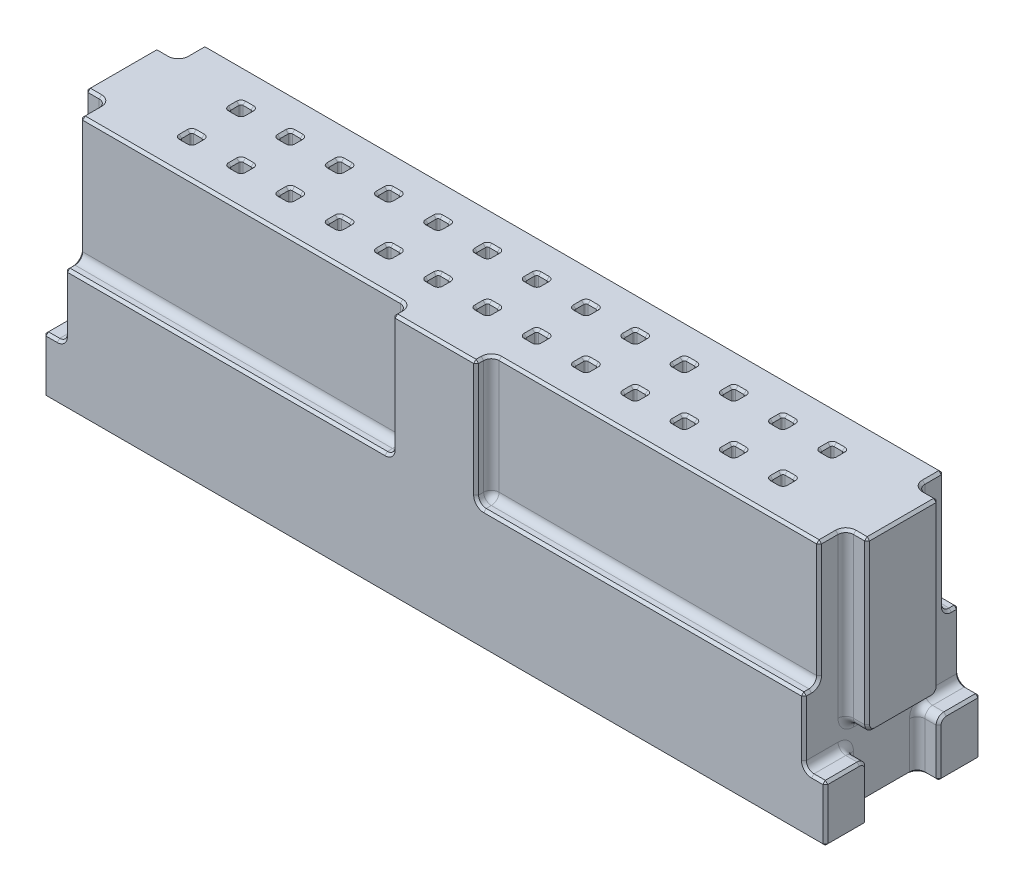
from build123d import *

# Parameters (mm, degrees)
SKETCH1_W            = 40.3098
SKETCH1_H            = 8.001
BOSS_EXTRUDE1_DEPTH  = 12.7
SKETCH2_W            = 1.1049
SKETCH2_H            = 2.159
CUT_EXTRUDE1_DEPTH   = 9.79932
CUT_EXTRUDE2_REACH   = 23.431
CUT_EXTRUDE2_START   = -8.73125
SKETCH4_W            = 1.1049
SKETCH4_H            = 3.683
SKETCH5_W            = 16.89989
SKETCH5_H            = 0.78613
SKETCH5_W_2          = 38.1
CUT_EXTRUDE3_DEPTH   = 6.4008
SKETCH6_W            = 0.61976
SKETCH6_H            = 0.61976
CUT_EXTRUDE4_DEPTH   = 6.10108
LPATTERN1_COUNT      = 13
LPATTERN1_PITCH      = 2.54
LPATTERN1_COUNT_DIR2 = 2
LPATTERN1_PITCH_DIR2 = 2.54
FILLET1_R            = 0.396875
FILLET3_R            = 0.09921875
CHAMFER1_SIZE        = 0.127


with BuildPart() as part:
    # Sketch1 → Boss-Extrude1 (new body)
    with BuildSketch(Plane(origin=(0, 0, 0), x_dir=(1, 0, 0), z_dir=(0, 1, 0))):
        Rectangle(SKETCH1_W, SKETCH1_H)
    extrude(amount=BOSS_EXTRUDE1_DEPTH)

    # Sketch2 → Cut-Extrude1 (cut)
    with BuildSketch(Plane(origin=(0, 12.7, 0), x_dir=(1, 0, 0), z_dir=(0, 1, 0))):
        with Locations((-19.60245, 2.921)):
            Rectangle(SKETCH2_W, SKETCH2_H)
        with Locations((-19.60245, -2.921)):
            Rectangle(SKETCH2_W, SKETCH2_H)
        with Locations((19.60245, 2.921)):
            Rectangle(SKETCH2_W, SKETCH2_H)
        with Locations((19.60245, -2.921)):
            Rectangle(SKETCH2_W, SKETCH2_H)
    extrude(amount=-CUT_EXTRUDE1_DEPTH, mode=Mode.SUBTRACT)

    # Sketch4 → Cut-Extrude2 (cut, up to next)
    with BuildSketch(Plane(origin=(0, 12.7, 0), x_dir=(1, 0, 0), z_dir=(0, 1, 0)).offset(CUT_EXTRUDE2_START), mode=Mode.PRIVATE) as cut_extrude2_sk1:
        with Locations((-19.60245, 0)):
            Rectangle(SKETCH4_W, SKETCH4_H)
    cut_extrude2_tool1 = extrude(cut_extrude2_sk1.sketch, amount=-CUT_EXTRUDE2_REACH, mode=Mode.PRIVATE) & part.part
    add(cut_extrude2_tool1.solids().sort_by_distance((-19.60245, 3.96875, 0))[0], mode=Mode.SUBTRACT)
    # Sketch4 → Cut-Extrude2 (cut, up to next)
    with BuildSketch(Plane(origin=(0, 12.7, 0), x_dir=(1, 0, 0), z_dir=(0, 1, 0)).offset(CUT_EXTRUDE2_START), mode=Mode.PRIVATE) as cut_extrude2_sk2:
        with Locations((19.60245, 0)):
            Rectangle(SKETCH4_W, SKETCH4_H)
    cut_extrude2_tool2 = extrude(cut_extrude2_sk2.sketch, amount=-CUT_EXTRUDE2_REACH, mode=Mode.PRIVATE) & part.part
    add(cut_extrude2_tool2.solids().sort_by_distance((19.60245, 3.96875, 0))[0], mode=Mode.SUBTRACT)

    # Sketch5 → Cut-Extrude3 (cut)
    with BuildSketch(Plane(origin=(0, 12.7, 0), x_dir=(1, 0, 0), z_dir=(0, 1, 0))):
        with Locations((-10.600055, -3.607435)):
            Rectangle(SKETCH5_W, SKETCH5_H)
        with Locations((10.600055, -3.607435)):
            Rectangle(SKETCH5_W, SKETCH5_H)
        with Locations((0, 3.607435)):
            Rectangle(SKETCH5_W_2, SKETCH5_H)
    extrude(amount=-CUT_EXTRUDE3_DEPTH, mode=Mode.SUBTRACT)

    # Sketch6 → Cut-Extrude4 (cut)
    with BuildSketch(Plane(origin=(0, 12.7, 0), x_dir=(1, 0, 0), z_dir=(0, 1, 0))):
        with Locations((-15.24, 1.27)):
            Rectangle(SKETCH6_W, SKETCH6_H)
    cut_extrude4 = extrude(amount=-CUT_EXTRUDE4_DEPTH, mode=Mode.SUBTRACT)

    # LPattern1: Cut-Extrude4 13 × 2
    with Locations(*[(i * LPATTERN1_PITCH, 0, j * LPATTERN1_PITCH_DIR2) for i in range(LPATTERN1_COUNT) for j in range(LPATTERN1_COUNT_DIR2) if (i, j) != (0, 0)]):
        add(cut_extrude4, mode=Mode.SUBTRACT)

    # Fillet1
    fillet1_edges = [part.edges().sort_by_distance(p)[0] for p in [
        (0, 6.2992, -3.21437),
        (10.600055, 6.2992, 3.21437),
        (2.15011, 9.4996, 3.21437),
        (2.15011, 6.2992, 3.607435),
        (-10.600055, 6.2992, 3.21437),
        (-2.15011, 6.2992, 3.607435),
        (-2.15011, 9.4996, 3.21437),
        (-19.60245, 2.90068, 1.8415),
        (-19.05, 2.90068, 2.921),
        (19.60245, 2.90068, -1.8415),
        (19.05, 2.90068, -2.921),
        (19.05, 2.90068, 2.921),
        (19.60245, 2.90068, 1.8415),
        (-19.05, 2.90068, -2.921),
        (-19.60245, 2.90068, -1.8415),
        (-19.05, 8.334375, 1.8415),
        (19.05, 8.334375, -1.8415),
        (19.05, 8.334375, 1.8415),
        (-19.05, 8.334375, -1.8415),
        (-19.05, 1.45034, 1.8415),
        (-19.05, 1.45034, -1.8415),
        (-19.60245, 3.96875, 1.8415),
        (-19.05, 3.96875, 0),
        (-19.60245, 3.96875, -1.8415),
        (19.05, 1.45034, -1.8415),
        (19.05, 1.45034, 1.8415),
        (19.60245, 3.96875, -1.8415),
        (19.05, 3.96875, 0),
        (19.60245, 3.96875, 1.8415),
    ]]
    fillet(fillet1_edges, radius=FILLET1_R)

    # Fillet3
    fillet3_edges = [part.edges().sort_by_distance(p)[0] for p in [
        (-15.54988, 9.64946, -0.96012),
        (-15.54988, 9.64946, -1.57988),
        (-14.93012, 6.59892, -1.27),
        (-14.93012, 9.64946, -1.57988),
        (-15.24, 6.59892, -0.96012),
        (-14.93012, 9.64946, -0.96012),
        (-15.54988, 6.59892, -1.27),
        (-15.24, 6.59892, -1.57988),
        (-13.00988, 9.64946, -0.96012),
        (-13.00988, 9.64946, -1.57988),
        (-12.39012, 6.59892, -1.27),
        (-12.39012, 9.64946, -1.57988),
        (-12.7, 6.59892, -0.96012),
        (-12.39012, 9.64946, -0.96012),
        (-13.00988, 6.59892, -1.27),
        (-12.7, 6.59892, -1.57988),
        (-10.46988, 9.64946, -0.96012),
        (-10.46988, 6.59892, -1.27),
        (-10.46988, 9.64946, -1.57988),
        (-10.16, 6.59892, -1.57988),
        (-9.85012, 9.64946, -1.57988),
        (-9.85012, 6.59892, -1.27),
        (-9.85012, 9.64946, -0.96012),
        (-10.16, 6.59892, -0.96012),
        (-7.92988, 9.64946, -0.96012),
        (-7.92988, 6.59892, -1.27),
        (-7.92988, 9.64946, -1.57988),
        (-7.62, 6.59892, -1.57988),
        (-7.31012, 9.64946, -1.57988),
        (-7.31012, 6.59892, -1.27),
        (-7.31012, 9.64946, -0.96012),
        (-7.62, 6.59892, -0.96012),
        (-5.38988, 9.64946, -0.96012),
        (-5.38988, 6.59892, -1.27),
        (-5.38988, 9.64946, -1.57988),
        (-5.08, 6.59892, -1.57988),
        (-4.77012, 9.64946, -1.57988),
        (-4.77012, 6.59892, -1.27),
        (-4.77012, 9.64946, -0.96012),
        (-5.08, 6.59892, -0.96012),
        (-2.84988, 9.64946, -0.96012),
        (-2.84988, 6.59892, -1.27),
        (-2.84988, 9.64946, -1.57988),
        (-2.54, 6.59892, -1.57988),
        (-2.23012, 9.64946, -1.57988),
        (-2.23012, 6.59892, -1.27),
        (-2.23012, 9.64946, -0.96012),
        (-2.54, 6.59892, -0.96012),
        (-0.30988, 9.64946, -0.96012),
        (-0.30988, 6.59892, -1.27),
        (-0.30988, 9.64946, -1.57988),
        (0, 6.59892, -1.57988),
        (0.30988, 9.64946, -1.57988),
        (0.30988, 6.59892, -1.27),
        (0.30988, 9.64946, -0.96012),
        (0, 6.59892, -0.96012),
        (2.23012, 9.64946, -0.96012),
        (2.23012, 6.59892, -1.27),
        (2.23012, 9.64946, -1.57988),
        (2.54, 6.59892, -1.57988),
        (2.84988, 9.64946, -1.57988),
        (2.84988, 6.59892, -1.27),
        (2.84988, 9.64946, -0.96012),
        (2.54, 6.59892, -0.96012),
        (4.77012, 9.64946, -0.96012),
        (4.77012, 6.59892, -1.27),
        (4.77012, 9.64946, -1.57988),
        (5.08, 6.59892, -1.57988),
        (5.38988, 9.64946, -1.57988),
        (5.38988, 6.59892, -1.27),
        (5.38988, 9.64946, -0.96012),
        (5.08, 6.59892, -0.96012),
        (7.31012, 9.64946, -0.96012),
        (7.31012, 6.59892, -1.27),
        (7.31012, 9.64946, -1.57988),
        (7.62, 6.59892, -1.57988),
        (7.92988, 9.64946, -1.57988),
        (7.92988, 6.59892, -1.27),
        (7.92988, 9.64946, -0.96012),
        (7.62, 6.59892, -0.96012),
        (9.85012, 9.64946, -0.96012),
        (9.85012, 6.59892, -1.27),
        (9.85012, 9.64946, -1.57988),
        (10.16, 6.59892, -1.57988),
        (10.46988, 9.64946, -1.57988),
        (10.46988, 6.59892, -1.27),
        (10.46988, 9.64946, -0.96012),
        (10.16, 6.59892, -0.96012),
        (12.39012, 9.64946, -0.96012),
        (12.39012, 6.59892, -1.27),
        (12.39012, 9.64946, -1.57988),
        (12.7, 6.59892, -1.57988),
        (13.00988, 9.64946, -1.57988),
        (13.00988, 6.59892, -1.27),
        (13.00988, 9.64946, -0.96012),
        (12.7, 6.59892, -0.96012),
        (14.93012, 9.64946, -0.96012),
        (14.93012, 6.59892, -1.27),
        (14.93012, 9.64946, -1.57988),
        (15.24, 6.59892, -1.57988),
        (15.54988, 9.64946, -1.57988),
        (15.54988, 6.59892, -1.27),
        (15.54988, 9.64946, -0.96012),
        (15.24, 6.59892, -0.96012),
        (-15.54988, 9.64946, 1.57988),
        (-15.54988, 6.59892, 1.27),
        (-15.54988, 9.64946, 0.96012),
        (-15.24, 6.59892, 0.96012),
        (-14.93012, 9.64946, 0.96012),
        (-14.93012, 6.59892, 1.27),
        (-14.93012, 9.64946, 1.57988),
        (-15.24, 6.59892, 1.57988),
        (-13.00988, 9.64946, 1.57988),
        (-13.00988, 6.59892, 1.27),
        (-13.00988, 9.64946, 0.96012),
        (-12.7, 6.59892, 0.96012),
        (-12.39012, 9.64946, 0.96012),
        (-12.39012, 6.59892, 1.27),
        (-12.39012, 9.64946, 1.57988),
        (-12.7, 6.59892, 1.57988),
        (-10.46988, 9.64946, 1.57988),
        (-10.46988, 6.59892, 1.27),
        (-10.46988, 9.64946, 0.96012),
        (-10.16, 6.59892, 0.96012),
        (-9.85012, 9.64946, 0.96012),
        (-9.85012, 6.59892, 1.27),
        (-9.85012, 9.64946, 1.57988),
        (-10.16, 6.59892, 1.57988),
        (-7.92988, 9.64946, 1.57988),
        (-7.92988, 6.59892, 1.27),
        (-7.92988, 9.64946, 0.96012),
        (-7.62, 6.59892, 0.96012),
        (-7.31012, 9.64946, 0.96012),
        (-7.31012, 6.59892, 1.27),
        (-7.31012, 9.64946, 1.57988),
        (-7.62, 6.59892, 1.57988),
        (-5.38988, 9.64946, 1.57988),
        (-5.38988, 6.59892, 1.27),
        (-5.38988, 9.64946, 0.96012),
        (-5.08, 6.59892, 0.96012),
        (-4.77012, 9.64946, 0.96012),
        (-4.77012, 6.59892, 1.27),
        (-4.77012, 9.64946, 1.57988),
        (-5.08, 6.59892, 1.57988),
        (-2.84988, 9.64946, 1.57988),
        (-2.84988, 6.59892, 1.27),
        (-2.84988, 9.64946, 0.96012),
        (-2.54, 6.59892, 0.96012),
        (-2.23012, 9.64946, 0.96012),
        (-2.23012, 6.59892, 1.27),
        (-2.23012, 9.64946, 1.57988),
        (-2.54, 6.59892, 1.57988),
        (-0.30988, 9.64946, 1.57988),
        (-0.30988, 6.59892, 1.27),
        (-0.30988, 9.64946, 0.96012),
        (0, 6.59892, 0.96012),
        (0.30988, 9.64946, 0.96012),
        (0.30988, 6.59892, 1.27),
        (0.30988, 9.64946, 1.57988),
        (0, 6.59892, 1.57988),
        (2.23012, 9.64946, 1.57988),
        (2.23012, 6.59892, 1.27),
        (2.23012, 9.64946, 0.96012),
        (2.54, 6.59892, 0.96012),
        (2.84988, 9.64946, 0.96012),
        (2.84988, 6.59892, 1.27),
        (2.84988, 9.64946, 1.57988),
        (2.54, 6.59892, 1.57988),
        (4.77012, 9.64946, 1.57988),
        (4.77012, 6.59892, 1.27),
        (4.77012, 9.64946, 0.96012),
        (5.08, 6.59892, 0.96012),
        (5.38988, 9.64946, 0.96012),
        (5.38988, 6.59892, 1.27),
        (5.38988, 9.64946, 1.57988),
        (5.08, 6.59892, 1.57988),
        (7.31012, 9.64946, 1.57988),
        (7.31012, 6.59892, 1.27),
        (7.31012, 9.64946, 0.96012),
        (7.62, 6.59892, 0.96012),
        (7.92988, 9.64946, 0.96012),
        (7.92988, 6.59892, 1.27),
        (7.92988, 9.64946, 1.57988),
        (7.62, 6.59892, 1.57988),
        (9.85012, 9.64946, 1.57988),
        (9.85012, 6.59892, 1.27),
        (9.85012, 9.64946, 0.96012),
        (10.16, 6.59892, 0.96012),
        (10.46988, 9.64946, 0.96012),
        (10.46988, 6.59892, 1.27),
        (10.46988, 9.64946, 1.57988),
        (10.16, 6.59892, 1.57988),
        (12.39012, 9.64946, 1.57988),
        (12.39012, 6.59892, 1.27),
        (12.39012, 9.64946, 0.96012),
        (12.7, 6.59892, 0.96012),
        (13.00988, 9.64946, 0.96012),
        (13.00988, 6.59892, 1.27),
        (13.00988, 9.64946, 1.57988),
        (12.7, 6.59892, 1.57988),
        (14.93012, 9.64946, 1.57988),
        (14.93012, 6.59892, 1.27),
        (14.93012, 9.64946, 0.96012),
        (15.24, 6.59892, 0.96012),
        (15.54988, 9.64946, 0.96012),
        (15.54988, 6.59892, 1.27),
        (15.54988, 9.64946, 1.57988),
        (15.24, 6.59892, 1.57988),
    ]]
    fillet(fillet3_edges, radius=FILLET3_R)

    # Chamfer1
    chamfer1_edges = [part.edges().sort_by_distance(p)[0] for p in [
        (-19.05, 12.7, 2.7263725),
        (19.05, 12.7, -2.7263725),
        (0, 12.7, 4.0005),
        (-19.05, 6.2992, -3.8058725),
        (0, 6.2992, -4.0005),
        (0, 12.7, -3.21437),
        (19.05, 6.2992, 3.8058725),
        (10.7984925, 12.7, 3.21437),
        (-10.7984925, 6.2992, 4.0005),
        (-2.15011, 12.7, 3.8058725),
        (-20.1549, 12.7, 0),
        (20.1549, 12.7, 0),
        (-20.1549, 1.45034, -4.0005),
        (20.1549, 1.45034, -4.0005),
        (20.1549, 1.45034, 4.0005),
        (-20.1549, 1.45034, 4.0005),
        (-19.8008875, 2.90068, 4.0005),
        (19.8008875, 2.90068, -4.0005),
        (20.1549, 2.90068, 3.1194375),
        (-19.8008875, 12.7, 1.8415),
        (-20.1549, 8.5328125, 1.8415),
        (-20.1549, 3.96875, 0),
        (-20.1549, 8.5328125, -1.8415),
        (-20.1549, 4.084991996, -1.725258004),
        (-20.1549, 4.084991996, 1.725258004),
        (-19.8008875, 2.90068, -4.0005),
        (19.8008875, 12.7, 1.8415),
        (-19.8008875, 0, -1.8415),
        (-20.1549, 2.784438004, -1.957741996),
        (-20.1549, 2.90068, 3.1194375),
        (-20.1549, 2.784438004, 1.957741996),
        (20.1549, 8.5328125, 1.8415),
        (20.1549, 3.96875, 0),
        (20.1549, 8.5328125, -1.8415),
        (20.1549, 4.084991996, -1.725258004),
        (20.1549, 4.084991996, 1.725258004),
        (19.8008875, 12.7, -1.8415),
        (19.8008875, 2.90068, 4.0005),
        (19.8008875, 0, 1.8415),
        (20.1549, 2.784438004, 1.957741996),
        (20.1549, 2.90068, -3.1194375),
        (20.1549, 2.784438004, -1.957741996),
        (19.05, 6.2992, -3.8058725),
        (19.05, 9.6980375, -3.21437),
        (19.05, 12.7, 2.7263725),
        (19.05, 9.6980375, 3.21437),
        (19.05, 4.7983775, 4.0005),
        (19.05, 0, 0),
        (19.05, 4.7983775, -4.0005),
        (-19.05, 12.7, -2.7263725),
        (-19.05, 9.6980375, -3.21437),
        (-19.05, 4.7983775, -4.0005),
        (-19.05, 0, 0),
        (-19.05, 4.7983775, 4.0005),
        (-19.05, 6.2992, 3.8058725),
        (-19.05, 9.6980375, 3.21437),
        (0, 0, 4.0005),
        (-10.7984925, 12.7, 3.21437),
        (-20.1549, 2.90068, -3.1194375),
        (-2.15011, 9.6980375, 4.0005),
        (10.7984925, 6.2992, 4.0005),
        (2.15011, 12.7, 3.8058725),
        (2.15011, 9.6980375, 4.0005),
        (19.166241996, 0, -1.725258004),
        (19.166241996, 3.016921996, -4.0005),
        (19.166241996, 0, 1.725258004),
        (19.166241996, 3.016921996, 4.0005),
        (-19.166241996, 3.016921996, 4.0005),
        (-19.166241996, 0, 1.725258004),
        (-19.166241996, 0, -1.725258004),
        (-19.166241996, 3.016921996, -4.0005),
        (19.166241996, 12.7, -1.957741996),
        (19.166241996, 12.7, 1.957741996),
        (-19.166241996, 12.7, 1.957741996),
        (-19.166241996, 12.7, -1.957741996),
        (19.05, 6.415441996, -3.330611996),
        (-19.05, 6.415441996, -3.330611996),
        (-19.05, 6.415441996, 3.330611996),
        (-2.266351996, 6.415441996, 4.0005),
        (-2.266351996, 12.7, 3.330611996),
        (2.266351996, 6.415441996, 4.0005),
        (19.05, 6.415441996, 3.330611996),
        (2.266351996, 12.7, 3.330611996),
        (-19.8008875, 12.7, -1.8415),
        (20.1549, 0, 2.921),
        (0, 0, -4.0005),
        (0, 12.7, -1.57988),
        (-20.1549, 0, 2.921),
        (0.30988, 12.7, -1.27),
        (2.23012, 12.7, -1.27),
        (2.54, 12.7, -1.57988),
        (2.84988, 12.7, -1.27),
        (2.54, 12.7, -0.96012),
        (4.77012, 12.7, -1.27),
        (5.08, 12.7, -1.57988),
        (5.38988, 12.7, -1.27),
        (5.08, 12.7, -0.96012),
        (7.31012, 12.7, -1.27),
        (7.62, 12.7, -1.57988),
        (7.92988, 12.7, -1.27),
        (7.62, 12.7, -0.96012),
        (9.85012, 12.7, -1.27),
        (10.16, 12.7, -1.57988),
        (10.46988, 12.7, -1.27),
        (10.16, 12.7, -0.96012),
        (12.39012, 12.7, -1.27),
        (12.7, 12.7, -1.57988),
        (13.00988, 12.7, -1.27),
        (12.7, 12.7, -0.96012),
        (14.93012, 12.7, -1.27),
        (15.24, 12.7, -1.57988),
        (15.54988, 12.7, -1.27),
        (15.24, 12.7, -0.96012),
        (-15.54988, 12.7, 1.27),
        (-15.24, 12.7, 0.96012),
        (-14.93012, 12.7, 1.27),
        (-15.24, 12.7, 1.57988),
        (-13.00988, 12.7, 1.27),
        (-12.7, 12.7, 0.96012),
        (-12.39012, 12.7, 1.27),
        (-12.7, 12.7, 1.57988),
        (-10.46988, 12.7, 1.27),
        (-10.16, 12.7, 0.96012),
        (-9.85012, 12.7, 1.27),
        (-10.16, 12.7, 1.57988),
        (-7.92988, 12.7, 1.27),
        (-7.62, 12.7, 0.96012),
        (-7.31012, 12.7, 1.27),
        (-7.62, 12.7, 1.57988),
        (-5.38988, 12.7, 1.27),
        (-5.08, 12.7, 0.96012),
        (-4.77012, 12.7, 1.27),
        (-5.08, 12.7, 1.57988),
        (-2.84988, 12.7, 1.27),
        (-2.54, 12.7, 0.96012),
        (-2.23012, 12.7, 1.27),
        (-2.54, 12.7, 1.57988),
        (-0.30988, 12.7, 1.27),
        (0, 12.7, 0.96012),
        (0.30988, 12.7, 1.27),
        (0, 12.7, 1.57988),
        (2.23012, 12.7, 1.27),
        (2.54, 12.7, 0.96012),
        (2.84988, 12.7, 1.27),
        (2.54, 12.7, 1.57988),
        (4.77012, 12.7, 1.27),
        (5.08, 12.7, 0.96012),
        (5.38988, 12.7, 1.27),
        (5.08, 12.7, 1.57988),
        (7.31012, 12.7, 1.27),
        (7.62, 12.7, 0.96012),
        (7.92988, 12.7, 1.27),
        (7.62, 12.7, 1.57988),
        (9.85012, 12.7, 1.27),
        (10.16, 12.7, 0.96012),
        (10.46988, 12.7, 1.27),
        (10.16, 12.7, 1.57988),
        (12.39012, 12.7, 1.27),
        (-20.1549, 0, -2.921),
        (12.7, 12.7, 0.96012),
        (13.00988, 12.7, 1.27),
        (20.1549, 0, -2.921),
        (12.7, 12.7, 1.57988),
        (14.93012, 12.7, 1.27),
        (15.24, 12.7, 0.96012),
        (15.54988, 12.7, 1.27),
        (15.24, 12.7, 1.57988),
        (-0.30988, 12.7, -1.27),
        (0, 12.7, -0.96012),
        (-2.54, 12.7, -0.96012),
        (-2.23012, 12.7, -1.27),
        (-2.54, 12.7, -1.57988),
        (-2.84988, 12.7, -1.27),
        (-5.08, 12.7, -0.96012),
        (-4.77012, 12.7, -1.27),
        (-5.08, 12.7, -1.57988),
        (-5.38988, 12.7, -1.27),
        (-7.62, 12.7, -0.96012),
        (-7.31012, 12.7, -1.27),
        (-7.62, 12.7, -1.57988),
        (-7.92988, 12.7, -1.27),
        (-10.16, 12.7, -0.96012),
        (-9.85012, 12.7, -1.27),
        (-10.16, 12.7, -1.57988),
        (-10.46988, 12.7, -1.27),
        (-12.7, 12.7, -0.96012),
        (-12.39012, 12.7, -1.27),
        (-12.7, 12.7, -1.57988),
        (-13.00988, 12.7, -1.27),
        (-19.8008875, 0, 1.8415),
        (-20.1549, 1.2519025, 1.8415),
        (-14.93012, 12.7, -1.27),
        (-20.1549, 1.2519025, -1.8415),
        (-15.24, 12.7, -0.96012),
        (-15.54988, 12.7, -1.27),
        (-15.24, 12.7, -1.57988),
        (14.959180499, 12.7, 1.550819501),
        (15.520819501, 12.7, 0.989180499),
        (14.959180499, 12.7, 0.989180499),
        (12.419180499, 12.7, 1.550819501),
        (12.980819501, 12.7, 1.550819501),
        (12.980819501, 12.7, 0.989180499),
        (12.419180499, 12.7, 0.989180499),
        (9.879180499, 12.7, 1.550819501),
        (10.440819501, 12.7, 1.550819501),
        (10.440819501, 12.7, 0.989180499),
        (9.879180499, 12.7, 0.989180499),
        (7.339180499, 12.7, 1.550819501),
        (7.900819501, 12.7, 1.550819501),
        (7.900819501, 12.7, 0.989180499),
        (7.339180499, 12.7, 0.989180499),
        (4.799180499, 12.7, 1.550819501),
        (5.360819501, 12.7, 1.550819501),
        (5.360819501, 12.7, 0.989180499),
        (4.799180499, 12.7, 0.989180499),
        (2.259180499, 12.7, 1.550819501),
        (2.820819501, 12.7, 1.550819501),
        (2.820819501, 12.7, 0.989180499),
        (2.259180499, 12.7, 0.989180499),
        (-0.280819501, 12.7, 1.550819501),
        (0.280819501, 12.7, 1.550819501),
        (0.280819501, 12.7, 0.989180499),
        (-0.280819501, 12.7, 0.989180499),
        (-2.820819501, 12.7, 1.550819501),
        (-2.259180499, 12.7, 1.550819501),
        (-2.259180499, 12.7, 0.989180499),
        (-2.820819501, 12.7, 0.989180499),
        (-5.360819501, 12.7, 1.550819501),
        (-4.799180499, 12.7, 1.550819501),
        (-4.799180499, 12.7, 0.989180499),
        (-5.360819501, 12.7, 0.989180499),
        (-7.900819501, 12.7, 1.550819501),
        (-7.339180499, 12.7, 1.550819501),
        (-7.339180499, 12.7, 0.989180499),
        (-7.900819501, 12.7, 0.989180499),
        (-10.440819501, 12.7, 1.550819501),
        (-9.879180499, 12.7, 1.550819501),
        (-9.879180499, 12.7, 0.989180499),
        (-10.440819501, 12.7, 0.989180499),
        (-12.980819501, 12.7, 1.550819501),
        (-12.419180499, 12.7, 1.550819501),
        (-12.419180499, 12.7, 0.989180499),
        (-12.980819501, 12.7, 0.989180499),
        (-15.520819501, 12.7, 1.550819501),
        (-14.959180499, 12.7, 1.550819501),
        (-14.959180499, 12.7, 0.989180499),
        (-15.520819501, 12.7, 0.989180499),
        (14.959180499, 12.7, -0.989180499),
        (15.520819501, 12.7, -0.989180499),
        (15.520819501, 12.7, -1.550819501),
        (14.959180499, 12.7, -1.550819501),
        (12.419180499, 12.7, -0.989180499),
        (12.980819501, 12.7, -0.989180499),
        (12.980819501, 12.7, -1.550819501),
        (12.419180499, 12.7, -1.550819501),
        (9.879180499, 12.7, -0.989180499),
        (10.440819501, 12.7, -0.989180499),
        (10.440819501, 12.7, -1.550819501),
        (9.879180499, 12.7, -1.550819501),
        (7.339180499, 12.7, -0.989180499),
        (7.900819501, 12.7, -0.989180499),
        (7.900819501, 12.7, -1.550819501),
        (7.339180499, 12.7, -1.550819501),
        (4.799180499, 12.7, -0.989180499),
        (5.360819501, 12.7, -0.989180499),
        (5.360819501, 12.7, -1.550819501),
        (4.799180499, 12.7, -1.550819501),
        (2.259180499, 12.7, -0.989180499),
        (2.820819501, 12.7, -0.989180499),
        (2.820819501, 12.7, -1.550819501),
        (2.259180499, 12.7, -1.550819501),
        (-0.280819501, 12.7, -0.989180499),
        (0.280819501, 12.7, -0.989180499),
        (0.280819501, 12.7, -1.550819501),
        (-0.280819501, 12.7, -1.550819501),
        (-2.820819501, 12.7, -0.989180499),
        (-2.259180499, 12.7, -0.989180499),
        (-2.259180499, 12.7, -1.550819501),
        (-2.820819501, 12.7, -1.550819501),
        (-5.360819501, 12.7, -0.989180499),
        (-4.799180499, 12.7, -0.989180499),
        (-4.799180499, 12.7, -1.550819501),
        (-5.360819501, 12.7, -1.550819501),
        (-7.900819501, 12.7, -0.989180499),
        (-7.339180499, 12.7, -0.989180499),
        (-7.339180499, 12.7, -1.550819501),
        (-7.900819501, 12.7, -1.550819501),
        (-10.440819501, 12.7, -0.989180499),
        (-9.879180499, 12.7, -0.989180499),
        (-9.879180499, 12.7, -1.550819501),
        (-10.440819501, 12.7, -1.550819501),
        (-12.980819501, 12.7, -0.989180499),
        (-12.419180499, 12.7, -0.989180499),
        (-12.419180499, 12.7, -1.550819501),
        (-12.980819501, 12.7, -1.550819501),
        (-15.520819501, 12.7, -0.989180499),
        (-14.959180499, 12.7, -0.989180499),
        (-14.959180499, 12.7, -1.550819501),
        (-15.520819501, 12.7, -1.550819501),
        (15.520819501, 12.7, 1.550819501),
        (19.8008875, 0, -1.8415),
        (20.1549, 1.2519025, -1.8415),
        (20.1549, 1.2519025, 1.8415),
    ]]
    chamfer(chamfer1_edges, length=CHAMFER1_SIZE)


solid = part.part
